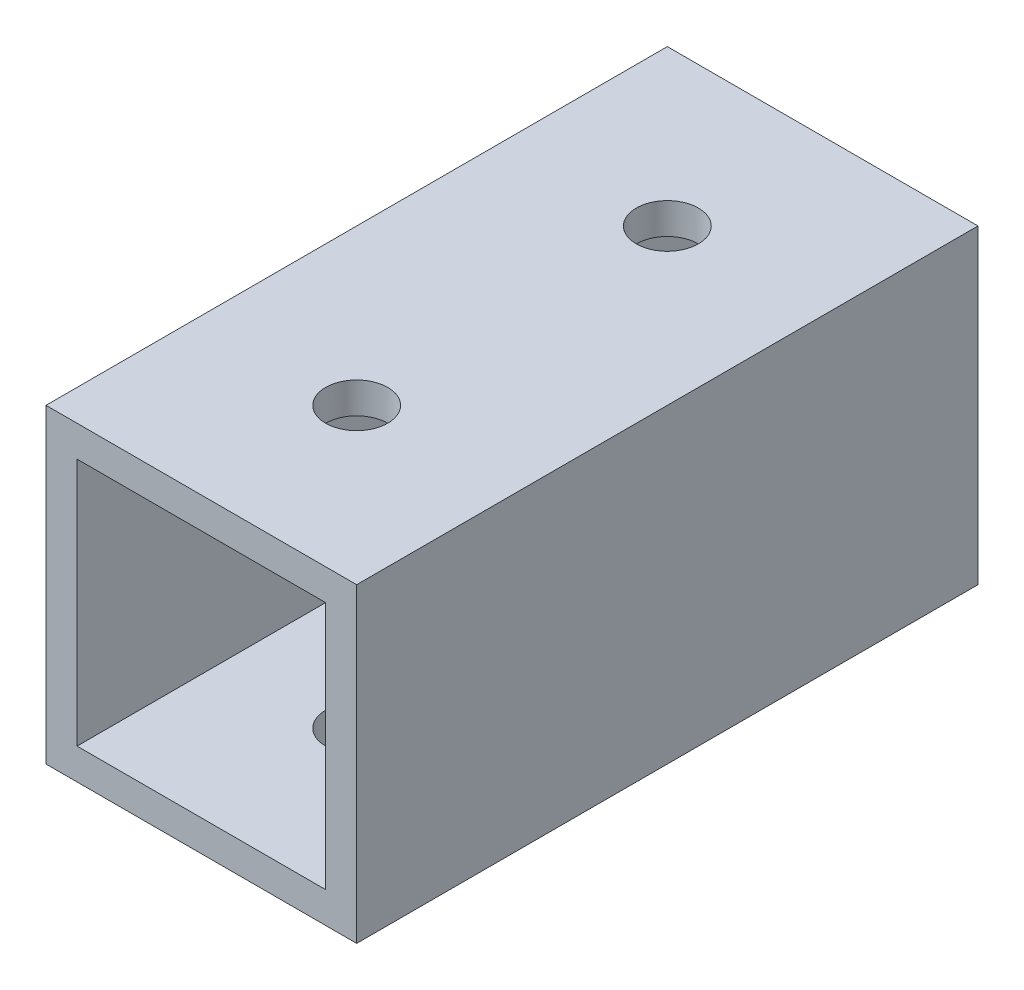
from build123d import *

# Parameters (mm, degrees)
SKETCH_1_W          = 15
SKETCH_1_H          = 15
SKETCH_1_W_2        = 12
SKETCH_1_H_2        = 12
EXTRUDE_2_DEPTH     = 30
SKETCH_2_R          = 1.5
CUT_EXTRUDE_1_DEPTH = 20
SKETCH_3_R          = 1.5
CUT_EXTRUDE_2_DEPTH = 10


with BuildPart() as part:
    # ｽｹｯﾁ1 → ﾎﾞｽ - 押し出し2 (new body)
    with BuildSketch(Plane.XY):
        with Locations((0.489915859, 0.232626086)):
            Rectangle(SKETCH_1_W, SKETCH_1_H)
        with Locations((0.489915859, 0.232626086)):
            Rectangle(SKETCH_1_W_2, SKETCH_1_H_2, mode=Mode.SUBTRACT)
    extrude(amount=EXTRUDE_2_DEPTH)

    # ｽｹｯﾁ2 → ｶｯﾄ - 押し出し1 (cut)
    with BuildSketch(Plane(origin=(0, 7.732626086, 0), x_dir=(1, 0, 0), z_dir=(0, 1, 0))):
        with Locations((0.489915859, -22.5)):
            Circle(SKETCH_2_R)
    extrude(amount=-CUT_EXTRUDE_1_DEPTH, mode=Mode.SUBTRACT)

    # ｽｹｯﾁ3 → ｶｯﾄ - 押し出し2 (cut)
    with BuildSketch(Plane(origin=(0, 7.732626086, 0), x_dir=(1, 0, 0), z_dir=(0, 1, 0))):
        with Locations((0.489915859, -7.5)):
            Circle(SKETCH_3_R)
    extrude(amount=-CUT_EXTRUDE_2_DEPTH, mode=Mode.SUBTRACT)


solid = part.part
